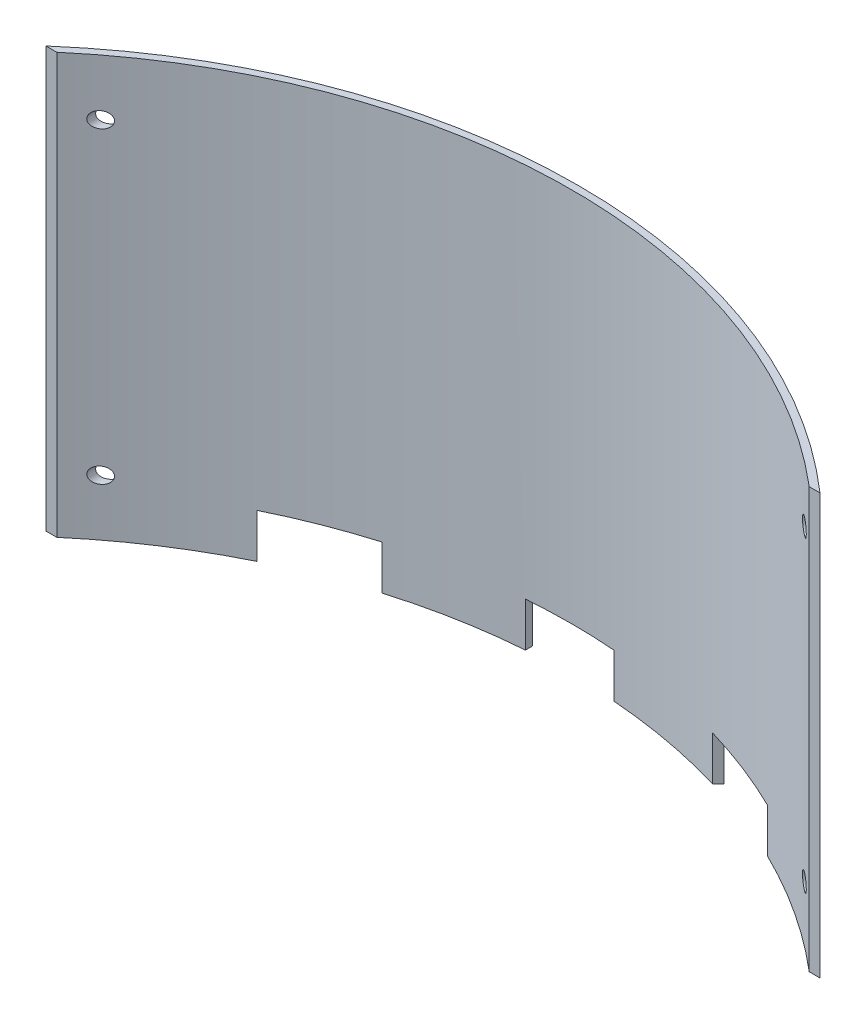
from build123d import *

# Parameters (mm, degrees)
CURVED_PLATE_DEPTH   = 190
IR_CUTOUT_DEPTH      = 20
SKETCH3_R            = 3.5687
MOUNTING_HOLES_DEPTH = 66.75


with BuildPart() as part:
    # Sketch1 → Curved Plate (new body)
    with BuildSketch(Plane(origin=(0, 0, 0), x_dir=(1, 0, 0), z_dir=(0, 1, 0))):
        with BuildLine():
            Line((170.139573777, 0), (175, 0))
            ThreePointArc((175, 0), (0, 65.75), (-175, 0))
            Line((-175, 0), (-170.139573777, 0))
            ThreePointArc((-170.139573777, 0), (0, 62.575), (170.139573777, 0))
        make_face()
    extrude(amount=CURVED_PLATE_DEPTH)

    # Sketch2 → IR Cutout (cut)
    with BuildSketch(Plane(origin=(0, 0, 0), x_dir=(1, 0, 0), z_dir=(0, 1, 0))):
        with BuildLine():
            Line((-117.762328859, 38.234983169), (-105.521942389, 25.994596699))
            Line((-105.521942389, 25.994596699), (-101.986408483, 22.459062793))
            Line((-101.986408483, 22.459062793), (-73.702137236, 50.743334041))
            Line((-73.702137236, 50.743334041), (-77.237671141, 54.278867947))
            ThreePointArc((-77.237671141, 54.278867947), (-97.829451392, 47.089074697), (-117.762328859, 38.234983169))
        make_face()
        with BuildLine():
            Line((77.237671141, 54.278867947), (73.702137236, 50.743334041))
            Line((73.702137236, 50.743334041), (101.986408483, 22.459062793))
            Line((101.986408483, 22.459062793), (105.521942389, 25.994596699))
            Line((105.521942389, 25.994596699), (117.762328859, 38.234983169))
            ThreePointArc((117.762328859, 38.234983169), (97.829451392, 47.089074697), (77.237671141, 54.278867947))
        make_face()
        with BuildLine():
            Line((-20, 64.996386215), (-20, 59.996386215))
            Line((-20, 59.996386215), (20, 59.996386215))
            Line((20, 59.996386215), (20, 64.996386215))
            ThreePointArc((20, 64.996386215), (0, 65.75), (-20, 64.996386215))
        make_face()
    extrude(amount=IR_CUTOUT_DEPTH, mode=Mode.SUBTRACT)

    # Sketch3 → Mounting Holes (cut, through all)
    with BuildSketch(Plane.XY):
        with Locations((-159.125, 164.6)):
            Circle(SKETCH3_R)
        with Locations((-159.125, 25.4)):
            Circle(SKETCH3_R)
        with Locations((159.125, 25.4)):
            Circle(SKETCH3_R)
        with Locations((159.125, 164.6)):
            Circle(SKETCH3_R)
    extrude(amount=-MOUNTING_HOLES_DEPTH, mode=Mode.SUBTRACT)


solid = part.part
